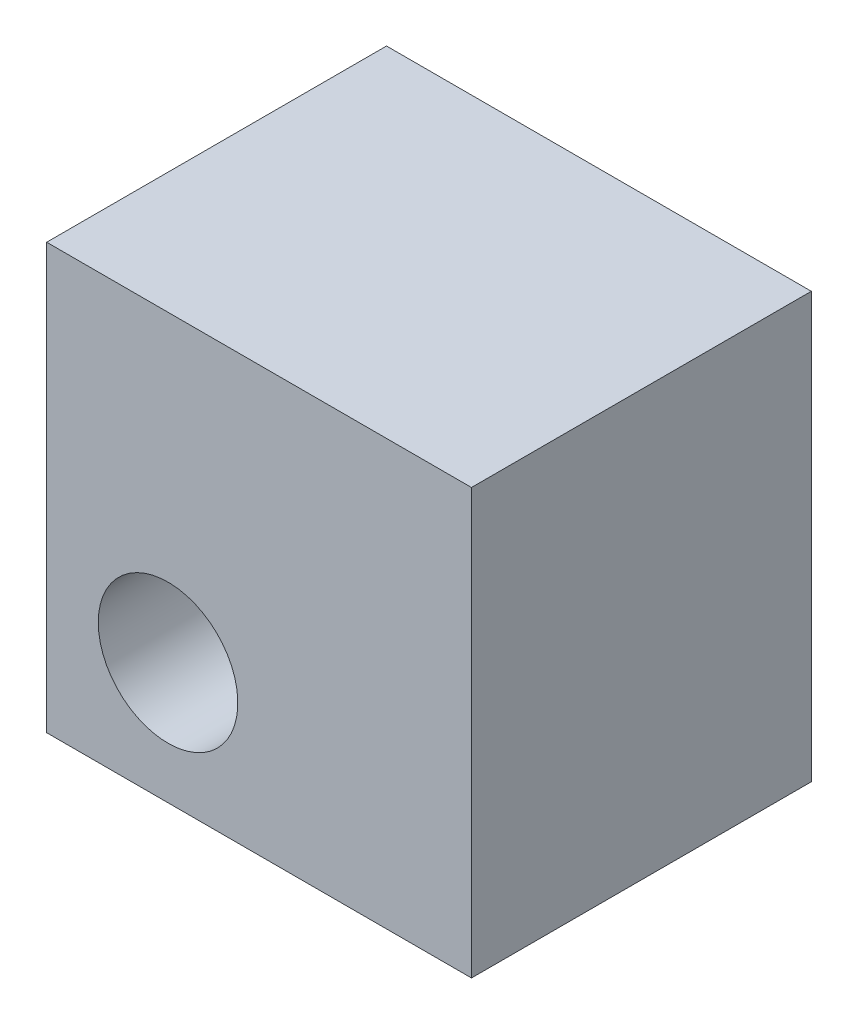
from build123d import *

# Parameters (mm, degrees)
ESQUISSE1_W             = 7
ESQUISSE1_H             = 7
BOSS_EXTRU_1_DEPTH      = 5.6
ESQUISSE2_W             = 4.5
ESQUISSE2_H             = 4.5
ENL_V_MAT_EXTRU_1_DEPTH = 1.6
ESQUISSE3_R             = 1.15
ENL_V_MAT_EXTRU_2_DEPTH = 11.6


with BuildPart() as part:
    # Esquisse1 → Boss.-Extru.1 (new body)
    with BuildSketch(Plane.XY):
        with Locations((3.5, 3.5)):
            Rectangle(ESQUISSE1_W, ESQUISSE1_H)
    extrude(amount=BOSS_EXTRU_1_DEPTH)

    # Esquisse2 → Enlèv. mat.-Extru.1 (cut)
    with BuildSketch(Plane.XY):
        with Locations((2.25, 2.25)):
            Rectangle(ESQUISSE2_W, ESQUISSE2_H)
    extrude(amount=ENL_V_MAT_EXTRU_1_DEPTH, mode=Mode.SUBTRACT)

    # Esquisse3 → Enlèv. mat.-Extru.2 (cut)
    with BuildSketch(Plane.XY):
        with Locations((2, 2)):
            Circle(ESQUISSE3_R)
    extrude(amount=ENL_V_MAT_EXTRU_2_DEPTH, mode=Mode.SUBTRACT)


solid = part.part
